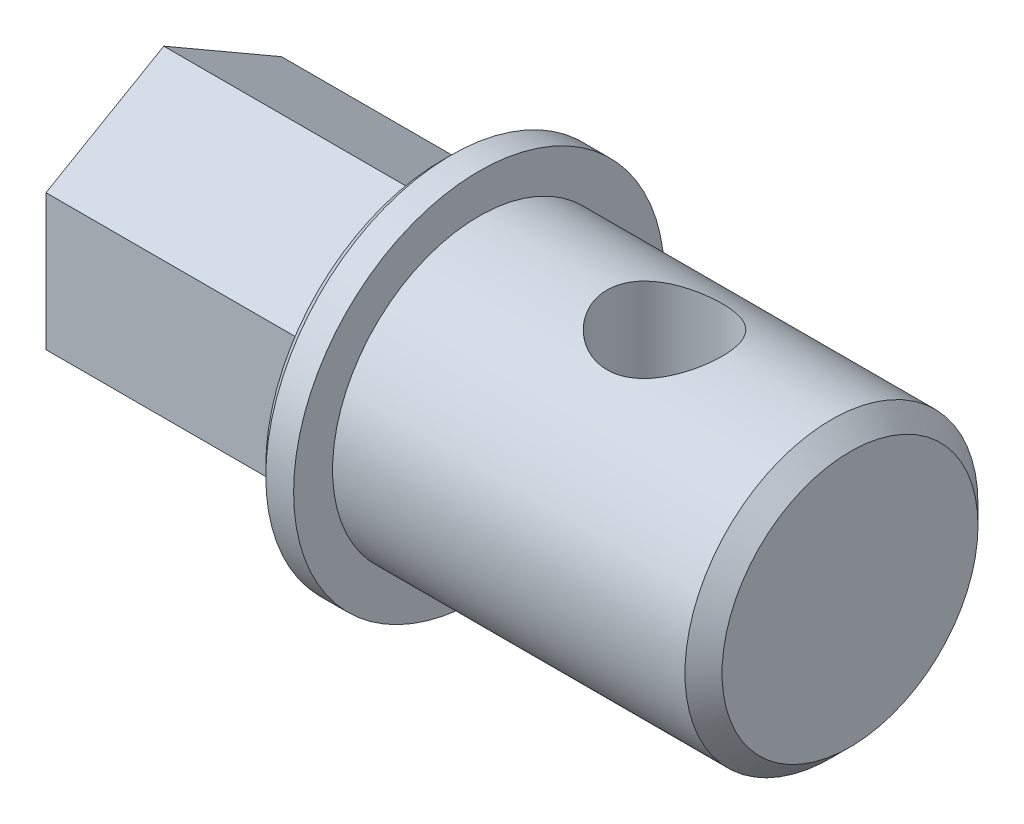
from build123d import *

# Parameters (mm, degrees)
SKETCH_1_R          = 7.9
EXTRUDE_1_DEPTH     = 20
SKETCH_3_R          = 10
EXTRUDE_2_DEPTH     = 2
EXTRUDE_3_DEPTH     = 15
SKETCH_5_R          = 3.1
CUT_EXTRUDE_1_DEPTH = 10
CHAMFER_1_SIZE      = 0.5
SKETCH_6_R          = 2.6
CUT_EXTRUDE_2_DEPTH = 15
CHAMFER_2_SIZE      = 1


with BuildPart() as part:
    # 草图1 → 凸台-拉伸1 (new body)
    with BuildSketch(Plane(origin=(0, 0, 0), x_dir=(0, 0, -1), z_dir=(1, 0, 0))):
        Circle(SKETCH_1_R)
    extrude(amount=EXTRUDE_1_DEPTH)

    # 草图3 → 凸台-拉伸2 (add)
    with BuildSketch(Plane.ZY):
        Circle(SKETCH_3_R)
    extrude(amount=EXTRUDE_2_DEPTH)

    # 草图4 → 凸台-拉伸3 (add)
    with BuildSketch(Plane.ZY.offset(2)):
        Polygon((6.35, 3.666174209), (0, 7.332348419), (-6.35, 3.666174209), (-6.35, -3.666174209), (0, -7.332348419), (6.35, -3.666174209), align=None)
    extrude(amount=EXTRUDE_3_DEPTH)

    # 草图5 → 切除-拉伸1 (cut, symmetric)
    with BuildSketch(Plane(origin=(0, 0, 0), x_dir=(1, 0, 0), z_dir=(0, 1, 0))):
        with Locations((10, 0)):
            Circle(SKETCH_5_R)
    extrude(amount=CUT_EXTRUDE_1_DEPTH, both=True, mode=Mode.SUBTRACT)

    # 倒角1
    chamfer_1_edges = [part.edges().sort_by_distance(p)[0] for p in [
        (-2, 0, -10),
    ]]
    chamfer(chamfer_1_edges, length=CHAMFER_1_SIZE)

    # 草图6 → 切除-拉伸2 (cut)
    with BuildSketch(Plane.ZY.offset(17)):
        Circle(SKETCH_6_R)
    extrude(amount=-CUT_EXTRUDE_2_DEPTH, mode=Mode.SUBTRACT)

    # 倒角2
    chamfer_2_edges = [part.edges().sort_by_distance(p)[0] for p in [
        (20, 0, 7.9),
    ]]
    chamfer(chamfer_2_edges, length=CHAMFER_2_SIZE)


solid = part.part
